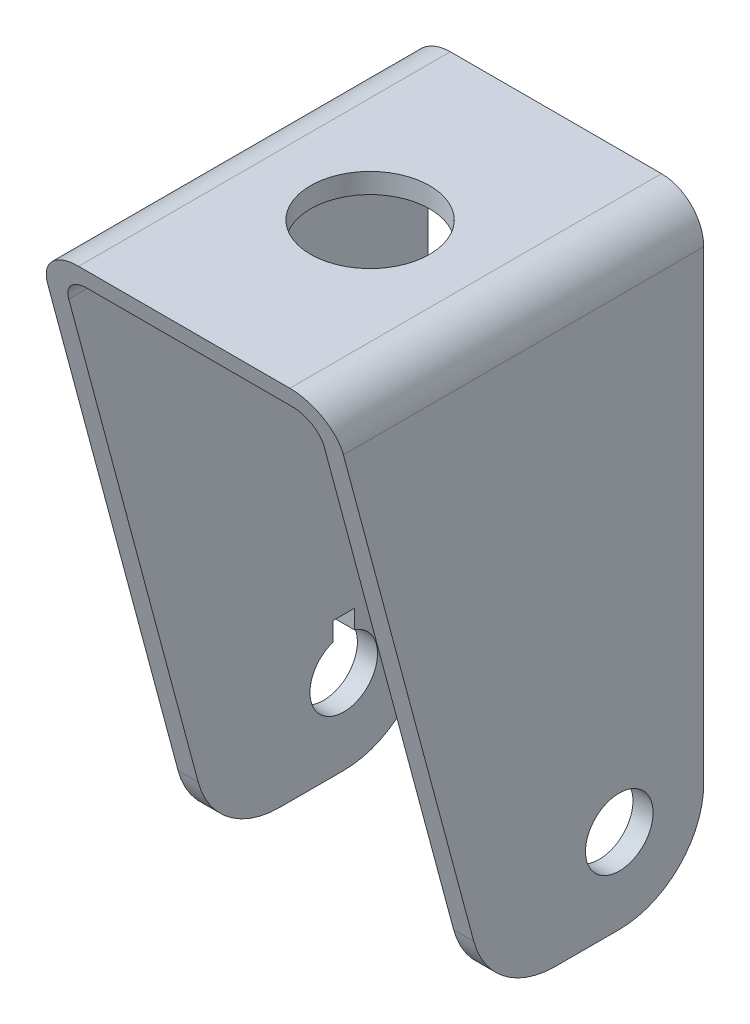
from build123d import *

# Parameters (mm, degrees)
BOSS_EXTRUDE1_DEPTH = 22
CUT_EXTRUDE1_DEPTH  = 18.5
SKETCH4_R           = 4
CUT_EXTRUDE2_DEPTH  = 18.5
FILLET2_R           = 10
FILLET3_R           = 10
SKETCH5_R           = 7.05
CUT_EXTRUDE3_DEPTH  = 71
CUT_EXTRUDE6_REACH  = 37


with BuildPart() as part:
    # Sketch1 → Boss-Extrude1 (new body, symmetric)
    with BuildSketch(Plane.XY):
        with BuildLine():
            Line((0, 0), (12.5, 0))
            ThreePointArc((12.5, 0), (16.035533906, -1.464466094), (17.5, -5))
            Line((17.5, -5), (17.5, -70))
            Line((17.5, -70), (15.12, -70))
            Line((15.12, -70), (15.12, -5.38))
            ThreePointArc((15.12, -5.38), (14.241320344, -3.258679656), (12.12, -2.38))
            Line((12.12, -2.38), (0, -2.38))
            Line((0, -2.38), (0, 0))
        make_face()
    extrude(amount=BOSS_EXTRUDE1_DEPTH, both=True)

    # Sketch3 → Cut-Extrude1 (cut, through all)
    with BuildSketch(Plane(origin=(17.5, 0, 0), x_dir=(0, 0, -1), z_dir=(1, 0, 0))):
        Polygon((-22, 0), (-22, -70), (-3.24355653, -70), align=None)
    extrude(amount=-CUT_EXTRUDE1_DEPTH, mode=Mode.SUBTRACT)

    # Sketch4 → Cut-Extrude2 (cut, through all)
    with BuildSketch(Plane(origin=(17.5, 0, 0), x_dir=(0, 0, -1), z_dir=(1, 0, 0))):
        with Locations((12, -60)):
            Circle(SKETCH4_R)
    extrude(amount=-CUT_EXTRUDE2_DEPTH, mode=Mode.SUBTRACT)

    # Fillet2
    fillet2_edges = [part.edges().sort_by_distance(p)[0] for p in [
        (16.31, -70, -22),
    ]]
    fillet(fillet2_edges, radius=FILLET2_R)

    # Fillet3
    fillet3_edges = [part.edges().sort_by_distance(p)[0] for p in [
        (16.31, -70, 3.24355653),
    ]]
    fillet(fillet3_edges, radius=FILLET3_R)

    # Mirror1: part across plane


with BuildPart() as part_1:
    add(part.part)
    add(part.part.mirror(Plane(origin=(0, 0, 0), x_dir=(0, 0, 1), z_dir=(1, 0, 0))))

    # Sketch5 → Cut-Extrude3 (cut, through all)
    with BuildSketch(Plane(origin=(0, 0, 0), x_dir=(1, 0, 0), z_dir=(0, 1, 0))):
        Circle(SKETCH5_R)
    extrude(amount=-CUT_EXTRUDE3_DEPTH, mode=Mode.SUBTRACT)

    # Sketch7 → Cut-Extrude6 (cut, up to next)
    with BuildSketch(Plane.ZY.offset(17.5), mode=Mode.PRIVATE) as cut_extrude6_sk1:
        Polygon((-13.25, -54), (-10.75, -54), (-10.75, -56.200328962), (-10.75, -56.332123316), (-13.25, -56.332123316), (-13.25, -56.200328962), align=None)
    cut_extrude6_tool1 = extrude(cut_extrude6_sk1.sketch, amount=-CUT_EXTRUDE6_REACH, mode=Mode.PRIVATE) & part_1.part
    add(cut_extrude6_tool1.solids().sort_by_distance((-17.5, -55.166062, -12))[0], mode=Mode.SUBTRACT)


solid = part_1.part
